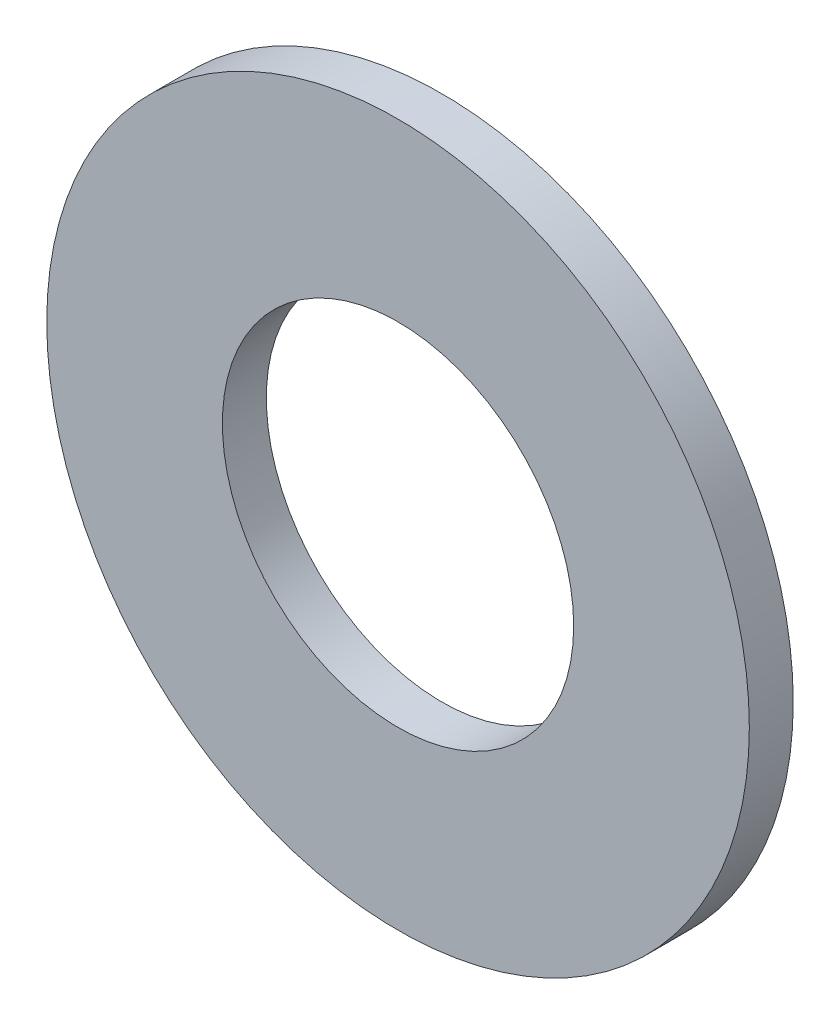
from build123d import *

# Parameters (mm, degrees)
SKETCH_1_R      = 4
SKETCH_1_R_2    = 2
EXTRUDE_1_DEPTH = 0.5


with BuildPart() as part:
    # 草图1 → 凸台-拉伸1 (new body)
    with BuildSketch(Plane.XY):
        Circle(SKETCH_1_R)
        Circle(SKETCH_1_R_2, mode=Mode.SUBTRACT)
    extrude(amount=EXTRUDE_1_DEPTH)


solid = part.part
